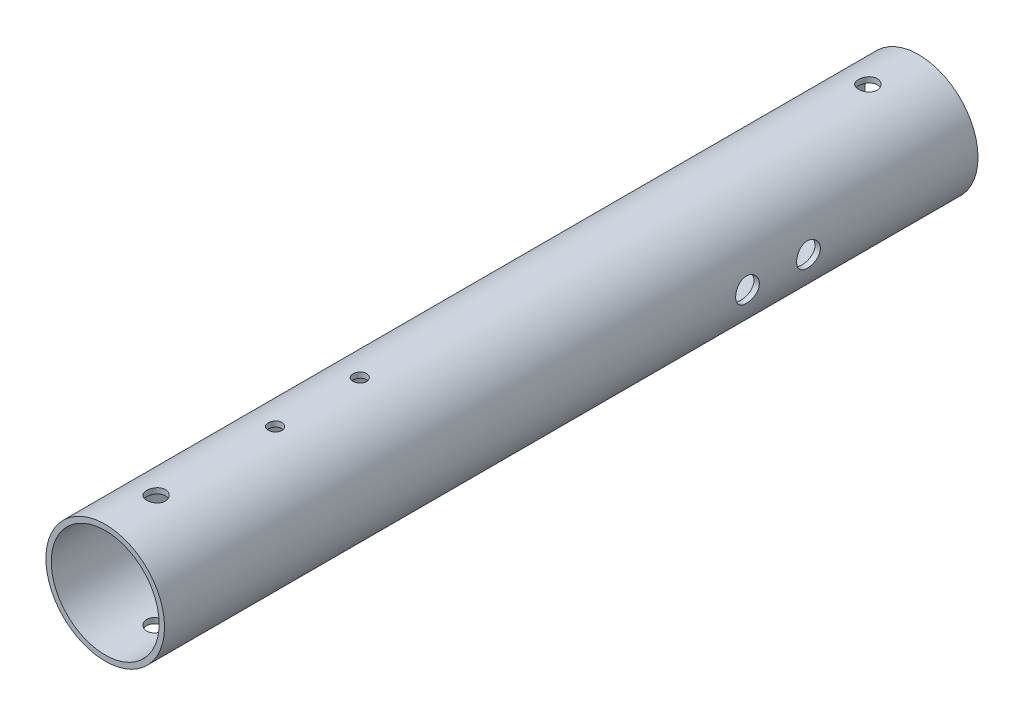
from build123d import *

# Parameters (mm, degrees)
SKETCH2_R                                  = 17.5
SKETCH2_R_2                                = 15.9125
BOSS_EXTRUDE1_DEPTH                        = 120
SKETCH6_W                                  = 2.75
SKETCH6_H                                  = 17.5
MIRROR1_AT_THE_SECOND_PLANE_COPY_1_SKETC_W = 2.75
MIRROR1_AT_THE_SECOND_PLANE_COPY_1_SKETC_H = 17.5
SKETCH7_R                                  = 3.5
CUT_EXTRUDE1_DEPTH                         = 18.5000001
CUT_EXTRUDE1_DEPTH_BACK                    = 18.5000001
SKETCH8_R                                  = 2
CUT_EXTRUDE2_DEPTH                         = 18.5000001
CUT_EXTRUDE2_DEPTH_BACK                    = 18.5000001


with BuildPart() as part:
    # Sketch2 → Boss-Extrude1 (new body, symmetric)
    with BuildSketch(Plane.XY):
        Circle(SKETCH2_R)
        Circle(SKETCH2_R_2, mode=Mode.SUBTRACT)
    extrude(amount=BOSS_EXTRUDE1_DEPTH, both=True)

    # Sketch6 → M5 Clearance Hole1 (revolve, cut)
    with BuildSketch(Plane(origin=(0, 0, -105), x_dir=(0, 0, -1), z_dir=(1, 0, 0))):
        with Locations((1.375, 8.75)):
            Rectangle(SKETCH6_W, SKETCH6_H)
    m5_clearance_hole1 = revolve(axis=Axis((0, -6.35, -105), (0, 1, 0)), mode=Mode.SUBTRACT)

    # Mirror1: M5 Clearance Hole1 across plane
    add(m5_clearance_hole1.mirror(Plane.XY), mode=Mode.SUBTRACT)

    # Mirror1 at the second plane: M5 Clearance Hole1 across plane
    add(m5_clearance_hole1.mirror(Plane.ZX), mode=Mode.SUBTRACT)

    # Mirror1 at the second plane copy 1 sketc → Mirror1 at the second plane copy 1 (revolve, cut)
    with BuildSketch(Plane(origin=(0, 0, 105), x_dir=(0, 0, 1), z_dir=(1, 0, 0))):
        with Locations((1.375, 8.75)):
            Rectangle(MIRROR1_AT_THE_SECOND_PLANE_COPY_1_SKETC_W, MIRROR1_AT_THE_SECOND_PLANE_COPY_1_SKETC_H)
    revolve(axis=Axis((0, 6.35, 105), (0, -1, 0)), mode=Mode.SUBTRACT)

    # Sketch7 → Cut-Extrude1 (cut, two sides)
    with BuildSketch(Plane(origin=(0, 0, 0), x_dir=(0, 0, -1), z_dir=(1, 0, 0))) as cut_extrude1_sk:
        with Locations((52, 0)):
            Circle(SKETCH7_R)
        with Locations((70, 0)):
            Circle(SKETCH7_R)
    extrude(amount=CUT_EXTRUDE1_DEPTH, mode=Mode.SUBTRACT)
    extrude(cut_extrude1_sk.sketch, amount=-CUT_EXTRUDE1_DEPTH_BACK, mode=Mode.SUBTRACT)

    # Sketch8 → Cut-Extrude2 (cut, two sides)
    with BuildSketch(Plane(origin=(0, 0, 0), x_dir=(1, 0, 0), z_dir=(0, 1, 0))) as cut_extrude2_sk:
        with Locations((0, -69.915016912)):
            Circle(SKETCH8_R)
        with Locations((0, -44.915016912)):
            Circle(SKETCH8_R)
    extrude(amount=CUT_EXTRUDE2_DEPTH, mode=Mode.SUBTRACT)
    extrude(cut_extrude2_sk.sketch, amount=-CUT_EXTRUDE2_DEPTH_BACK, mode=Mode.SUBTRACT)


solid = part.part
